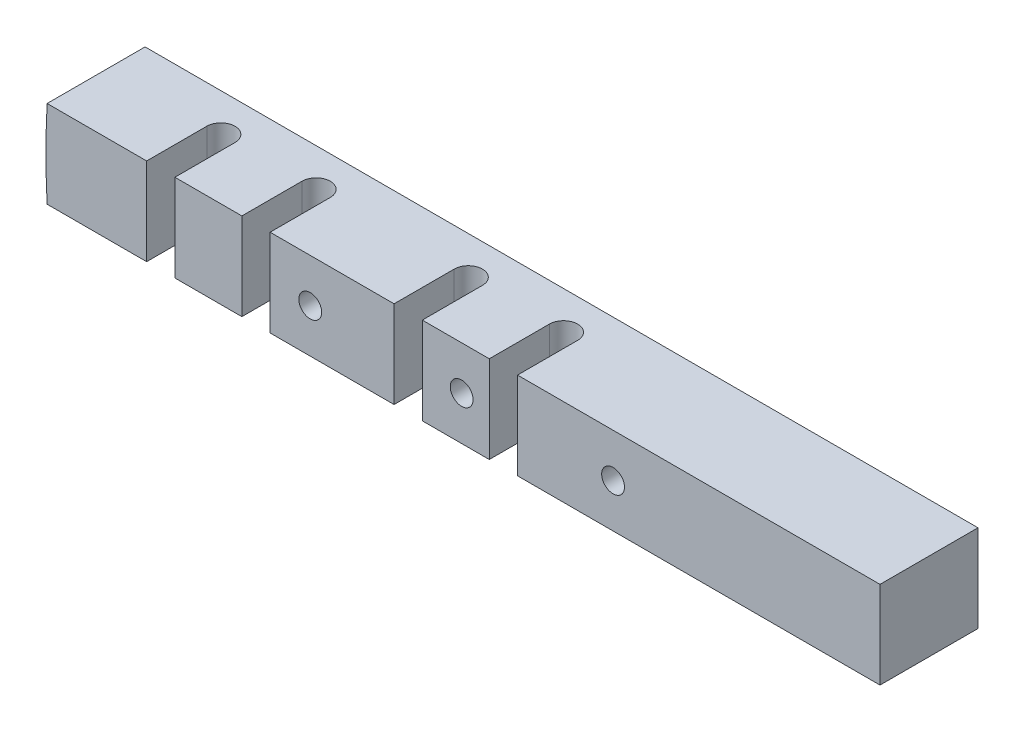
from build123d import *

# Parameters (mm, degrees)
BOSS_EXTRUDE2_DEPTH = 13.97
CUT_EXTRUDE1_DEPTH  = 9.636
SKETCH4_W           = 0.89408
SKETCH4_H           = 14.808934263
CUT_EXTRUDE2_DEPTH  = 9.636
SKETCH5_W           = 110.36886563
SKETCH5_H           = 6.670389245
CUT_EXTRUDE3_DEPTH  = 9.636
SKETCH6_R           = 1.1303
CUT_EXTRUDE4_DEPTH  = 5.08


with BuildPart() as part:
    # Sketch2 → Boss-Extrude2 (new body)
    with BuildSketch(Plane.XY):
        with BuildLine():
            Line((7.49808, 4.318), (-75.823148128, 4.318))
            ThreePointArc((-75.823148128, 4.318), (-75.946, 0), (-75.823148128, -4.318))
            Line((-75.823148128, -4.318), (7.49808, -4.318))
            Line((7.49808, -4.318), (7.49808, 4.318))
        make_face()
    extrude(amount=BOSS_EXTRUDE2_DEPTH)

    # Sketch3 → Cut-Extrude1 (cut, through all)
    with BuildSketch(Plane(origin=(0, -4.318, 0), x_dir=(-1, 0, 0), z_dir=(0, -1, 0))):
        with BuildLine():
            Line((63.17742, -10.2235), (63.17742, -3.7465))
            ThreePointArc((63.17742, -3.7465), (64.57442, -2.3495), (65.97142, -3.7465))
            Line((65.97142, -3.7465), (65.97142, -10.2235))
            ThreePointArc((65.97142, -10.2235), (64.57442, -11.6205), (63.17742, -10.2235))
        make_face()
        with BuildLine():
            Line((29.26842, -10.2235), (29.26842, -3.7465))
            ThreePointArc((29.26842, -3.7465), (30.66542, -2.3495), (32.06242, -3.7465))
            Line((32.06242, -3.7465), (32.06242, -10.2235))
            ThreePointArc((32.06242, -10.2235), (30.66542, -11.6205), (29.26842, -10.2235))
        make_face()
        with BuildLine():
            Line((38.69182, -10.2235), (38.69182, -3.7465))
            ThreePointArc((38.69182, -3.7465), (40.08882, -2.3495), (41.48582, -3.7465))
            Line((41.48582, -3.7465), (41.48582, -10.2235))
            ThreePointArc((41.48582, -10.2235), (40.08882, -11.6205), (38.69182, -10.2235))
        make_face()
        with BuildLine():
            Line((53.75402, -10.2235), (53.75402, -3.7465))
            ThreePointArc((53.75402, -3.7465), (55.15102, -2.3495), (56.54802, -3.7465))
            Line((56.54802, -3.7465), (56.54802, -10.2235))
            ThreePointArc((56.54802, -10.2235), (55.15102, -11.6205), (53.75402, -10.2235))
        make_face()
    extrude(amount=-CUT_EXTRUDE1_DEPTH, mode=Mode.SUBTRACT)

    # Sketch4 → Cut-Extrude2 (cut, through all)
    with BuildSketch(Plane.XZ.offset(4.318)):
        with Locations((7.05104, 6.565532869)):
            Rectangle(SKETCH4_W, SKETCH4_H)
    extrude(amount=-CUT_EXTRUDE2_DEPTH, mode=Mode.SUBTRACT)

    # Sketch5 → Cut-Extrude3 (cut, through all)
    with BuildSketch(Plane.XZ.offset(4.318)):
        with Locations((-32.153676927, 13.032670326)):
            Rectangle(SKETCH5_W, SKETCH5_H)
    extrude(amount=-CUT_EXTRUDE3_DEPTH, mode=Mode.SUBTRACT)

    # Sketch6 → Cut-Extrude4 (cut)
    with BuildSketch(Plane.XY.offset(9.697475704)):
        with Locations((-49.784, 0)):
            Circle(SKETCH6_R)
        with Locations((-34.798, 0)):
            Circle(SKETCH6_R)
        with Locations((-19.812, 0)):
            Circle(SKETCH6_R)
    extrude(amount=-CUT_EXTRUDE4_DEPTH, mode=Mode.SUBTRACT)


solid = part.part
